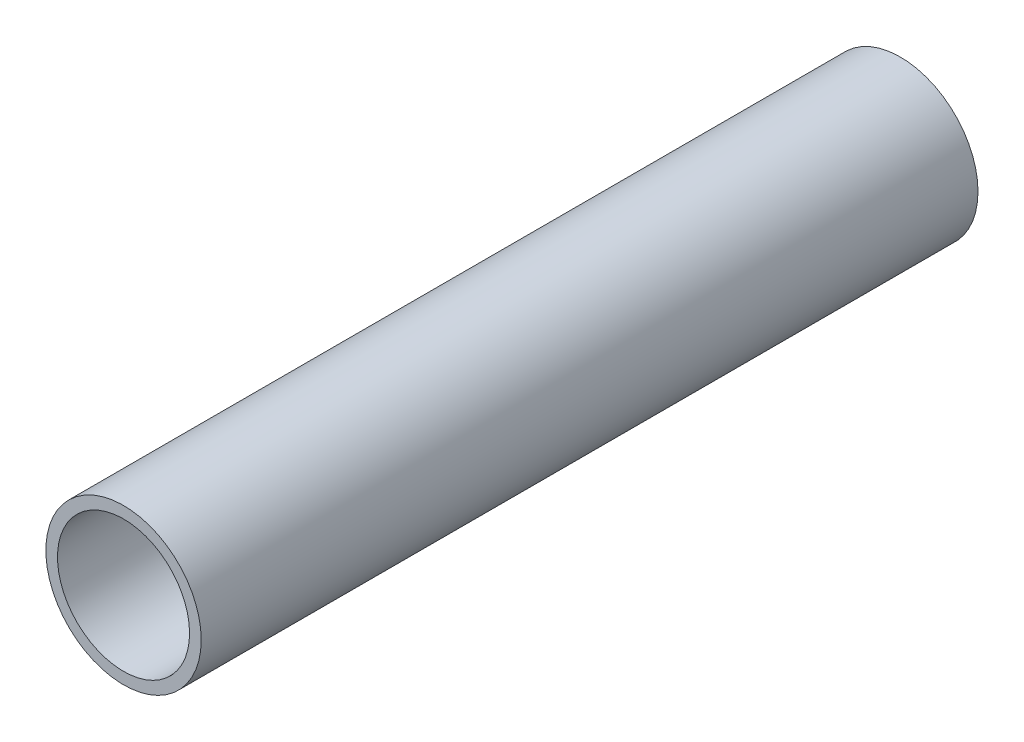
from build123d import *

# Parameters (mm, degrees)
SKETCH1_R           = 30
SKETCH1_R_2         = 25.5
BOSS_EXTRUDE1_DEPTH = 300


with BuildPart() as part:
    # Sketch1 → Boss-Extrude1 (new body)
    with BuildSketch(Plane.XY):
        Circle(SKETCH1_R)
        Circle(SKETCH1_R_2, mode=Mode.SUBTRACT)
    extrude(amount=BOSS_EXTRUDE1_DEPTH)


solid = part.part
